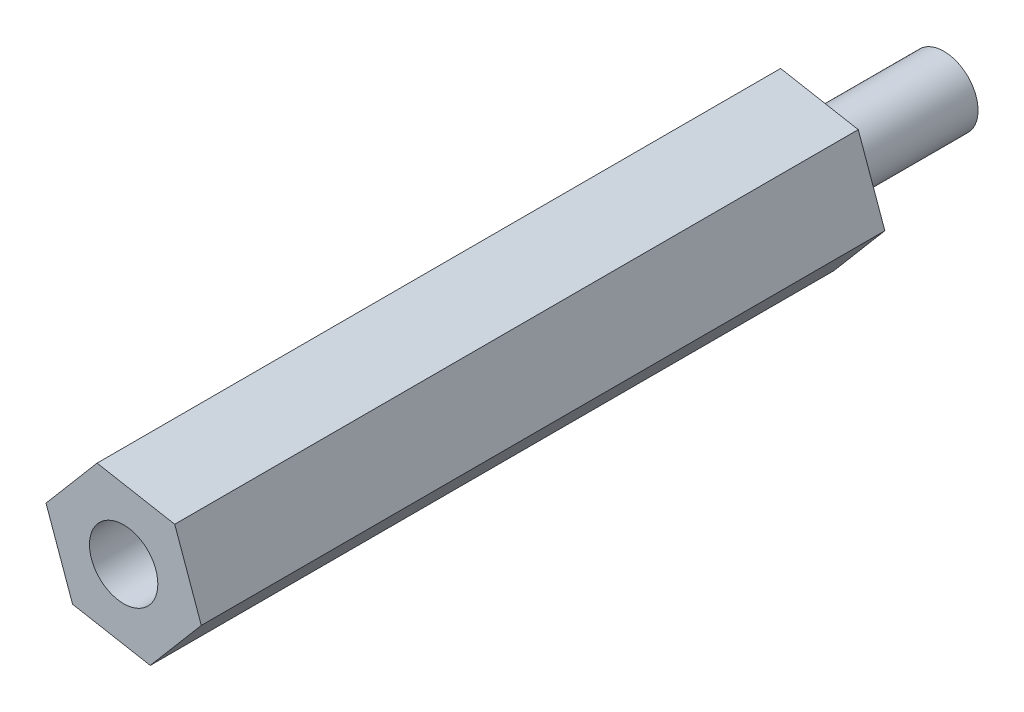
from build123d import *

# Parameters (mm, degrees)
RESSALTO_EXTRUS_O1_DEPTH = 30
ESBO_O4_R                = 1.5
CORTE_EXTRUS_O2_DEPTH    = 40
ESBO_O6_R                = 1.5
RESSALTO_EXTRUS_O2_DEPTH = 6


with BuildPart() as part:
    # Esboço1 → Ressalto-extrusão1 (new body)
    with BuildSketch(Plane.XY):
        Polygon((12.933175524, -4.143885809), (9.525050306, -3.523658029), (7.283854683, -6.165067156), (8.450784277, -9.426704064), (11.858909495, -10.046931845), (14.100105118, -7.405522718), align=None)
    extrude(amount=RESSALTO_EXTRUS_O1_DEPTH)

    # Esboço4 → Corte-extrusão2 (cut)
    with BuildSketch(Plane(origin=(0, 0, 0), x_dir=(-1, 0, 0), z_dir=(0, 0, -1))):
        with Locations((-10.691979901, -6.785294937)):
            Circle(ESBO_O4_R)
    extrude(amount=-CORTE_EXTRUS_O2_DEPTH, mode=Mode.SUBTRACT)


with BuildPart() as body_2:
    # Esboço6 → Ressalto-extrusão2 (new body)
    with BuildSketch(Plane(origin=(0, 0, 0), x_dir=(-1, 0, 0), z_dir=(0, 0, -1))):
        with Locations((-10.691979901, -6.785294937)):
            Circle(ESBO_O6_R)
    extrude(amount=RESSALTO_EXTRUS_O2_DEPTH)


solid = Compound([part.part, body_2.part])
